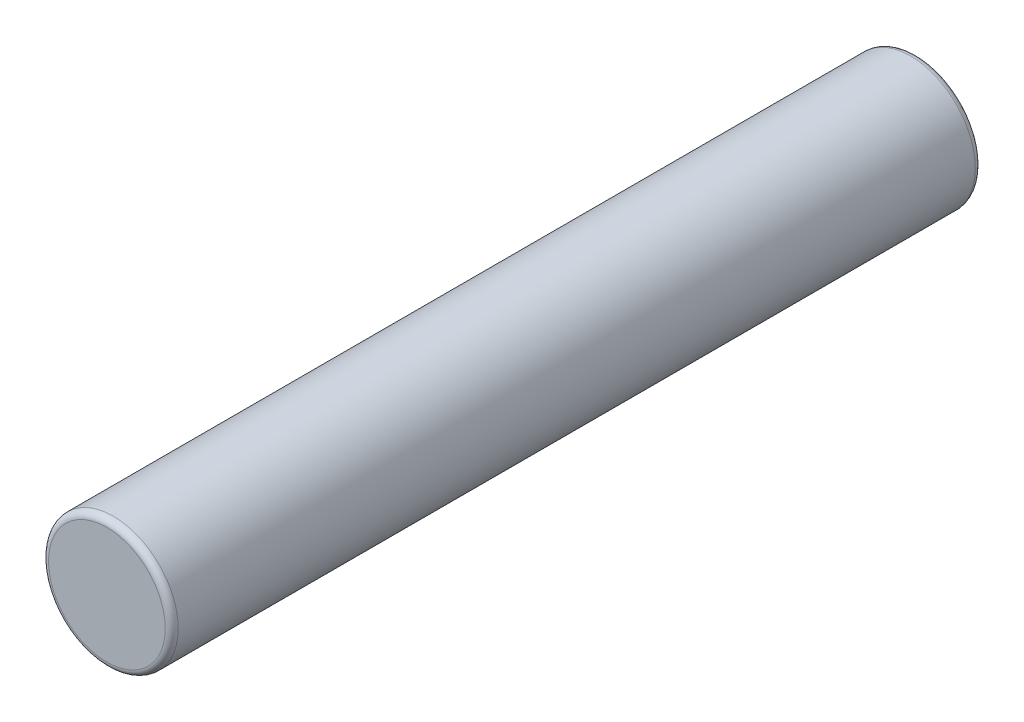
from build123d import *

# Parameters (mm, degrees)
SKIZZE1_R                       = 2
AUFSATZ_LINEAR_AUSTRAGEN1_DEPTH = 25
VERRUNDUNG2_R                   = 0.2


with BuildPart() as part:
    # Skizze1 → Aufsatz-Linear austragen1 (new body)
    with BuildSketch(Plane.XY):
        Circle(SKIZZE1_R)
    extrude(amount=AUFSATZ_LINEAR_AUSTRAGEN1_DEPTH)

    # Verrundung2
    verrundung2_edges = [part.edges().sort_by_distance(p)[0] for p in [
        (-2, 0, 0),
        (-2, 0, 25),
    ]]
    fillet(verrundung2_edges, radius=VERRUNDUNG2_R)


solid = part.part
